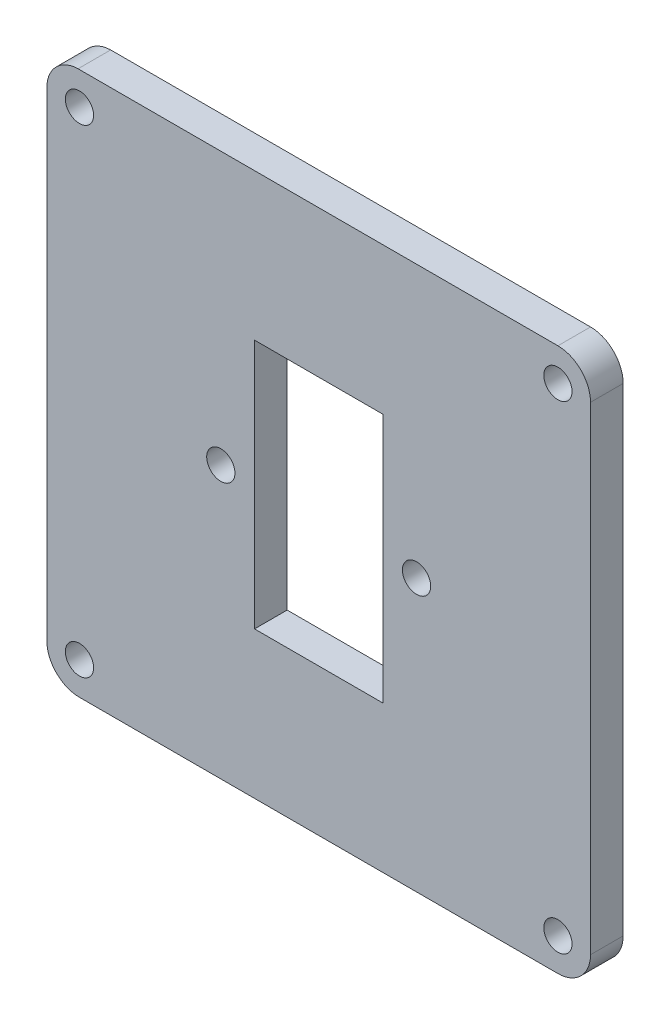
from build123d import *

# Parameters (mm, degrees)
MODEL_R             = 1.300000002
MODEL_R_2           = 1.299950005
MODEL_R_3           = 1.299950001
MODEL_W             = 11.8
MODEL_H             = 23
BOSS_EXTRUDE1_DEPTH = 3


with BuildPart() as part:
    # Model → Boss-Extrude1 (new body)
    with BuildSketch(Plane.XY):
        with BuildLine():
            Line((33.3225, 20.129700001), (33.3225, 64.129600001))
            ThreePointArc((33.3225, 64.129600001), (34.136296645, 66.222490163), (36.19171658, 67.126759536))
            Line((36.19171658, 67.126759536), (80.3225, 67.129600001))
            ThreePointArc((80.3225, 67.129600001), (82.4438375, 66.250937501), (83.3225, 64.129600001))
            Line((83.3225, 64.129600001), (83.3225, 20.129700001))
            ThreePointArc((83.3225, 20.129700001), (82.443835355, 18.008335356), (80.3225, 17.129600001))
            Line((80.3225, 17.129600001), (36.3225, 17.129600001))
            ThreePointArc((36.3225, 17.129600001), (34.201114643, 18.008285356), (33.3225, 20.129700001))
        make_face()
        with Locations((36.322500002, 64.129699999)):
            Circle(MODEL_R, mode=Mode.SUBTRACT)
        with Locations((80.322500002, 64.129699999)):
            Circle(MODEL_R, mode=Mode.SUBTRACT)
        with Locations((67.322549996, 42.129649997)):
            Circle(MODEL_R_2, mode=Mode.SUBTRACT)
        with Locations((49.32245, 42.129650001)):
            Circle(MODEL_R_3, mode=Mode.SUBTRACT)
        with Locations((36.322549996, 20.129649997)):
            Circle(MODEL_R_2, mode=Mode.SUBTRACT)
        with Locations((80.322549996, 20.129649997)):
            Circle(MODEL_R_2, mode=Mode.SUBTRACT)
        with Locations((58.3225, 42.129600001)):
            Rectangle(MODEL_W, MODEL_H, mode=Mode.SUBTRACT)
    extrude(amount=BOSS_EXTRUDE1_DEPTH)


solid = part.part
